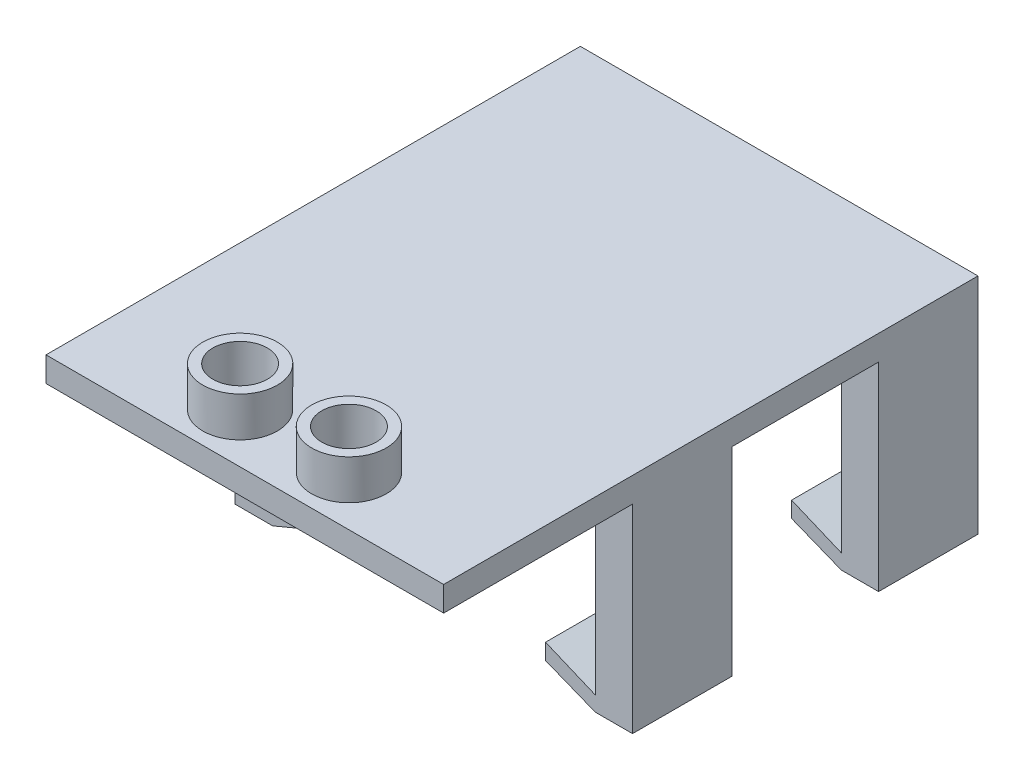
from build123d import *

# Parameters (mm, degrees)
SKETCH3_R           = 2.7813
BOSS_EXTRUDE3_DEPTH = 2.54
SKETCH4_W           = 3.81
SKETCH4_H           = 40.386
BOSS_EXTRUDE4_DEPTH = 20.32
SKETCH5_W           = 40.386
SKETCH5_H           = 1.524
BOSS_EXTRUDE5_DEPTH = 5.08
SKETCH6_W           = 40.386
SKETCH6_H           = 1.524
BOSS_EXTRUDE6_DEPTH = 5.08
SKETCH7_W           = 40.64
SKETCH7_H           = 20.32
CUT_EXTRUDE1_DEPTH  = 5.08
SKETCH11_W          = 40.64
SKETCH11_H          = 35.306
BOSS_EXTRUDE7_DEPTH = 2.9718
BOSS_EXTRUDE8_DEPTH = 35.306
SKETCH8_W           = 14.986
SKETCH8_H           = 20.32
CUT_EXTRUDE2_DEPTH  = 41.64
CUT_EXTRUDE3_DEPTH  = 36.306
SKETCH14_R          = 3.81
SKETCH14_R_2        = 2.7813
BOSS_EXTRUDE9_DEPTH = 6.604


with BuildPart() as part:
    # Sketch3 → Boss-Extrude3 (new body)
    with BuildSketch(Plane(origin=(0, 0, 0), x_dir=(1, 0, 0), z_dir=(0, 1, 0))):
        Polygon((-11.517251908, 12.440983784), (29.122748092, 12.440983784), (29.122748092, -34.564151764), (29.122748092, -42.169016216), (18.885256114, -42.169016216), (-11.517251908, -42.169016216), align=None)
        with Locations((3.240148092, -37.089016216)):
            Circle(SKETCH3_R, mode=Mode.SUBTRACT)
        with Locations((14.365348092, -37.089016216)):
            Circle(SKETCH3_R, mode=Mode.SUBTRACT)
    extrude(amount=BOSS_EXTRUDE3_DEPTH)

    # Sketch4 → Boss-Extrude4 (add)
    with BuildSketch(Plane.XZ):
        with Locations((-9.612251908, 7.752016216)):
            Rectangle(SKETCH4_W, SKETCH4_H)
        with Locations((27.217748092, 7.752016216)):
            Rectangle(SKETCH4_W, SKETCH4_H)
    extrude(amount=BOSS_EXTRUDE4_DEPTH)

    # Sketch5 → Boss-Extrude5 (add)
    with BuildSketch(Plane(origin=(-7.707251908, 0, 0), x_dir=(0, 0, -1), z_dir=(1, 0, 0))):
        with Locations((-7.752016216, -19.558)):
            Rectangle(SKETCH5_W, SKETCH5_H)
    extrude(amount=BOSS_EXTRUDE5_DEPTH)

    # Sketch6 → Boss-Extrude6 (add)
    with BuildSketch(Plane.ZY.offset(-25.312748092)):
        with Locations((7.752016216, -19.558)):
            Rectangle(SKETCH6_W, SKETCH6_H)
    extrude(amount=BOSS_EXTRUDE6_DEPTH)

    # Sketch7 → Cut-Extrude1 (cut)
    with BuildSketch(Plane.XY.offset(27.945016216)):
        with Locations((8.802748092, -10.16)):
            Rectangle(SKETCH7_W, SKETCH7_H)
    extrude(amount=-CUT_EXTRUDE1_DEPTH, mode=Mode.SUBTRACT)

    # Sketch11 → Boss-Extrude7 (add)
    with BuildSketch(Plane.XZ):
        with Locations((8.802748092, 5.212016216)):
            Rectangle(SKETCH11_W, SKETCH11_H)
    extrude(amount=BOSS_EXTRUDE7_DEPTH)

    # Sketch12 → Boss-Extrude8 (add)
    with BuildSketch(Plane.XY.offset(22.865016216)):
        Polygon((-7.707251908, -18.796), (-2.593407451, -16.66881978), (-2.627251908, -18.796), align=None)
        Polygon((20.232748092, -18.796), (20.232748092, -16.66881978), (25.312748092, -18.796), align=None)
    extrude(amount=-BOSS_EXTRUDE8_DEPTH)

    # Sketch8 → Cut-Extrude2 (cut, through all)
    with BuildSketch(Plane(origin=(29.122748092, 0, 0), x_dir=(0, 0, -1), z_dir=(1, 0, 0))):
        with Locations((-5.212016216, -10.16)):
            Rectangle(SKETCH8_W, SKETCH8_H)
    extrude(amount=-CUT_EXTRUDE2_DEPTH, mode=Mode.SUBTRACT)

    # Sketch13 → Cut-Extrude3 (cut, through all)
    with BuildSketch(Plane.XY.offset(22.865016216)):
        Polygon((-2.618031664, -18.216492377), (-7.660745747, -20.32), (-2.627251908, -20.32), (-2.627251908, -18.796), align=None)
        Polygon((20.232748092, -18.294602636), (20.232748092, -20.32), (25.312748092, -20.32), align=None)
    extrude(amount=-CUT_EXTRUDE3_DEPTH, mode=Mode.SUBTRACT)

    # Sketch14 → Boss-Extrude9 (add)
    with BuildSketch(Plane.XZ):
        with Locations((3.240148092, 37.089016216)):
            Circle(SKETCH14_R)
        with Locations((3.240148092, 37.089016216)):
            Circle(SKETCH14_R_2, mode=Mode.SUBTRACT)
        with Locations((14.365348092, 37.089016216)):
            Circle(SKETCH14_R)
        with Locations((14.365348092, 37.089016216)):
            Circle(SKETCH14_R_2, mode=Mode.SUBTRACT)
    extrude(amount=-BOSS_EXTRUDE9_DEPTH)


solid = part.part
